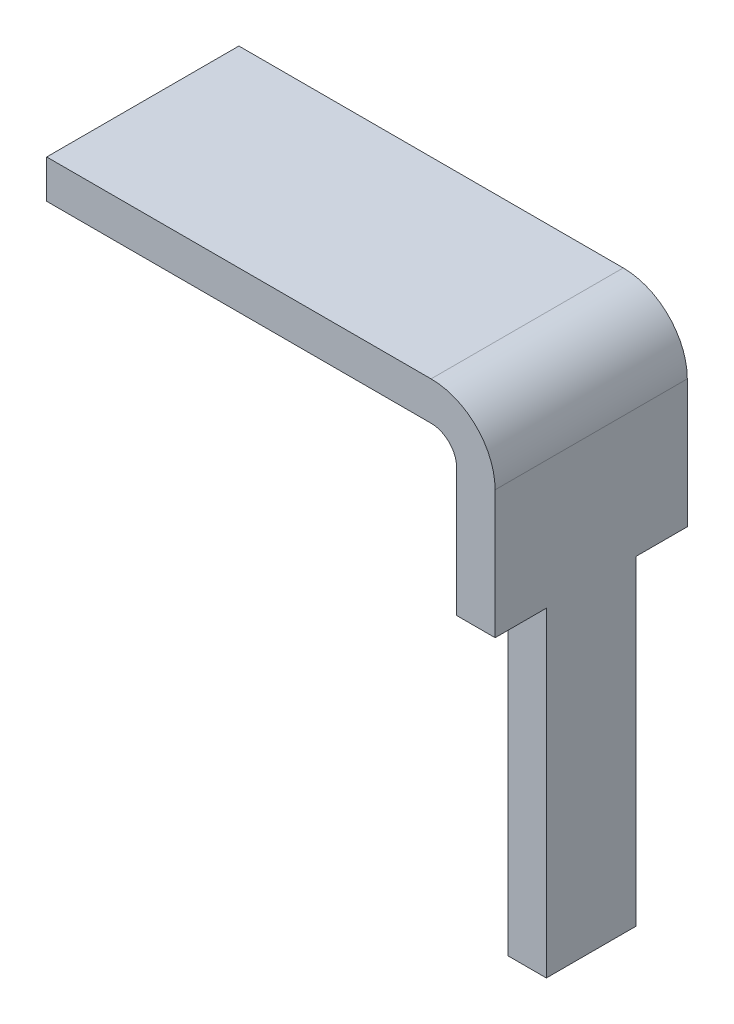
from build123d import *

# Parameters (mm, degrees)
BOSS_EXTRUDE1_DEPTH = 1.5
SKETCH2_W           = 0.4
SKETCH2_H           = 2.5
CUT_EXTRUDE1_DEPTH  = 1.5


with BuildPart() as part:
    # Sketch1 → Boss-Extrude1 (new body)
    with BuildSketch(Plane.XY):
        with BuildLine():
            Line((0, 0), (3, 0))
            ThreePointArc((3, 0), (3.353553391, -0.146446609), (3.5, -0.5))
            Line((3.5, -0.5), (3.5, -4))
            Line((3.5, -4), (3.2, -4))
            Line((3.2, -4), (3.2, -0.5))
            ThreePointArc((3.2, -0.5), (3.141421356, -0.358578644), (3, -0.3))
            Line((3, -0.3), (0, -0.3))
            Line((0, -0.3), (0, 0))
        make_face()
    extrude(amount=BOSS_EXTRUDE1_DEPTH)

    # Sketch2 → Cut-Extrude1 (cut)
    with BuildSketch(Plane(origin=(3.5, 0, 0), x_dir=(0, 0, -1), z_dir=(1, 0, 0))):
        with Locations((-1.3, -2.75)):
            Rectangle(SKETCH2_W, SKETCH2_H)
        with Locations((-0.2, -2.75)):
            Rectangle(SKETCH2_W, SKETCH2_H)
    extrude(amount=-CUT_EXTRUDE1_DEPTH, mode=Mode.SUBTRACT)


solid = part.part
